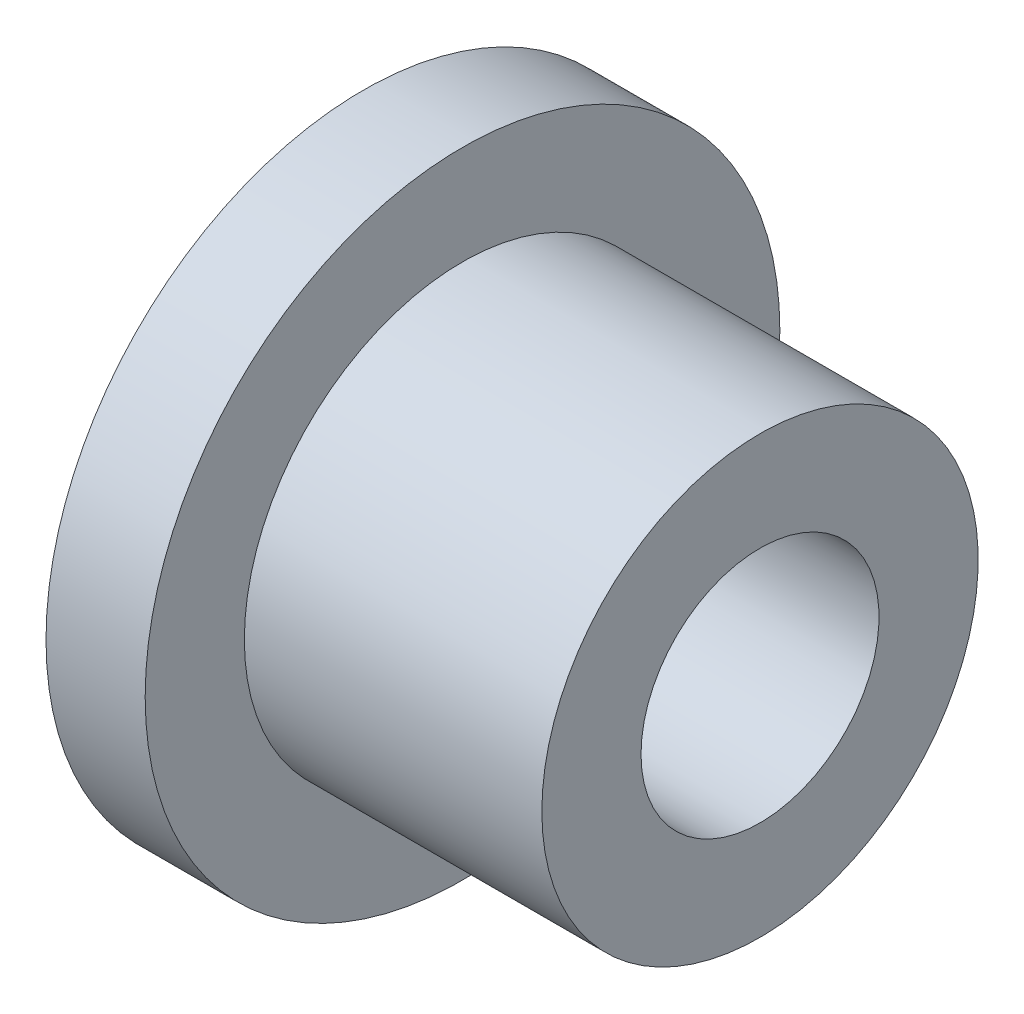
from build123d import *


with BuildPart() as part:
    # Sketch1 → Revolve1 (revolve)
    with BuildSketch(Plane.XY):
        Polygon((0, 6), (0, 16), (5, 16), (5, 11), (20, 11), (20, 6), align=None)
    revolve(axis=Axis((-20, 0, 0), (1, 0, 0)))


solid = part.part
